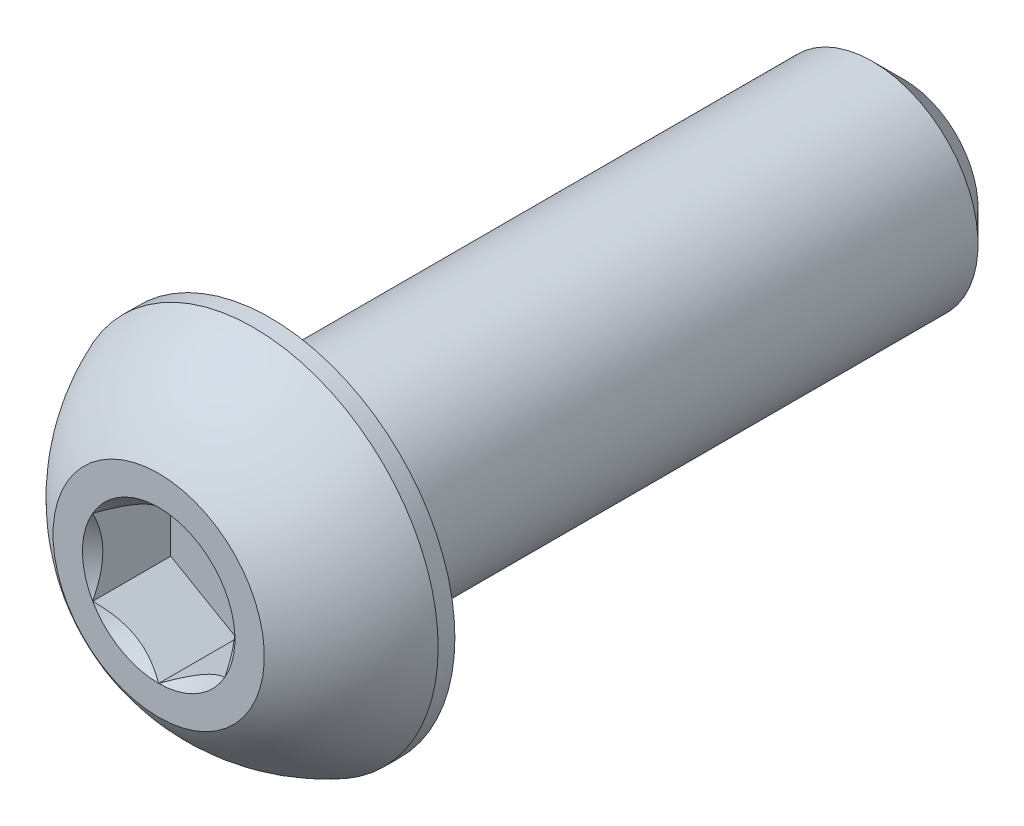
from build123d import *

# Parameters (mm, degrees)
SKETCH1_W          = 19.05
SKETCH1_H          = 3.175
CHAMFER1_SIZE      = 0.9525
CUT_EXTRUDE2_DEPTH = 2.34696


with BuildPart() as part:
    # Sketch1 → Revolve1 (revolve)
    with BuildSketch(Plane(origin=(0, 0, 0), x_dir=(0, 0, -1), z_dir=(1, 0, 0))):
        with Locations((12.8778, 1.5875)):
            Rectangle(SKETCH1_W, SKETCH1_H)
    revolve(axis=Axis((0, 0, -22.4028), (0, 0, 1)))

    # Chamfer1
    chamfer1_edges = [part.edges().sort_by_distance(p)[0] for p in [
        (0, -3.175, -22.4028),
    ]]
    chamfer(chamfer1_edges, length=CHAMFER1_SIZE)

    # Sketch7 → Revolve2 (revolve)
    with BuildSketch(Plane(origin=(0, 0, 0), x_dir=(0, 0, -1), z_dir=(1, 0, 0)), mode=Mode.PRIVATE) as revolve2_sk:
        with BuildLine():
            Line((2.84988, 5.5499), (3.3528, 5.5499))
            Line((3.3528, 5.5499), (3.3528, 0))
            Line((3.3528, 0), (0, 0))
            Line((0, 0), (0, 3.175))
            ThreePointArc((0, 3.175), (1.235921075, 4.58927271), (2.84988, 5.5499))
        make_face()
    revolve(revolve2_sk.sketch.rotate(Axis((0, 0, 0), (0, 0, -1)), 180), axis=Axis((0, 0, 0), (0, 0, -1)))

    # Sketch5 → Cut-Extrude2 (cut)
    with BuildSketch(Plane.XY):
        Polygon((1.984375, -1.14567944), (1.984375, 1.14567944), (0, 2.291358881), (-1.984375, 1.14567944), (-1.984375, -1.14567944), (0, -2.291358881), align=None)
    extrude(amount=-CUT_EXTRUDE2_DEPTH, mode=Mode.SUBTRACT)

    # Cut-Extrude3 cone 1 section (through the dimple's axis) → Cut-Extrude3 (revolve, cut)
    with BuildSketch(Plane(origin=(0, 0, 0), x_dir=(0, -1, 0), z_dir=(1, 0, 0))):
        Polygon((0, 0), (2.291358881, 0), (0, 2.291358881), align=None)
    revolve(axis=Axis((0, 0, 0), (0, 0, -1)), mode=Mode.SUBTRACT)


solid = part.part
